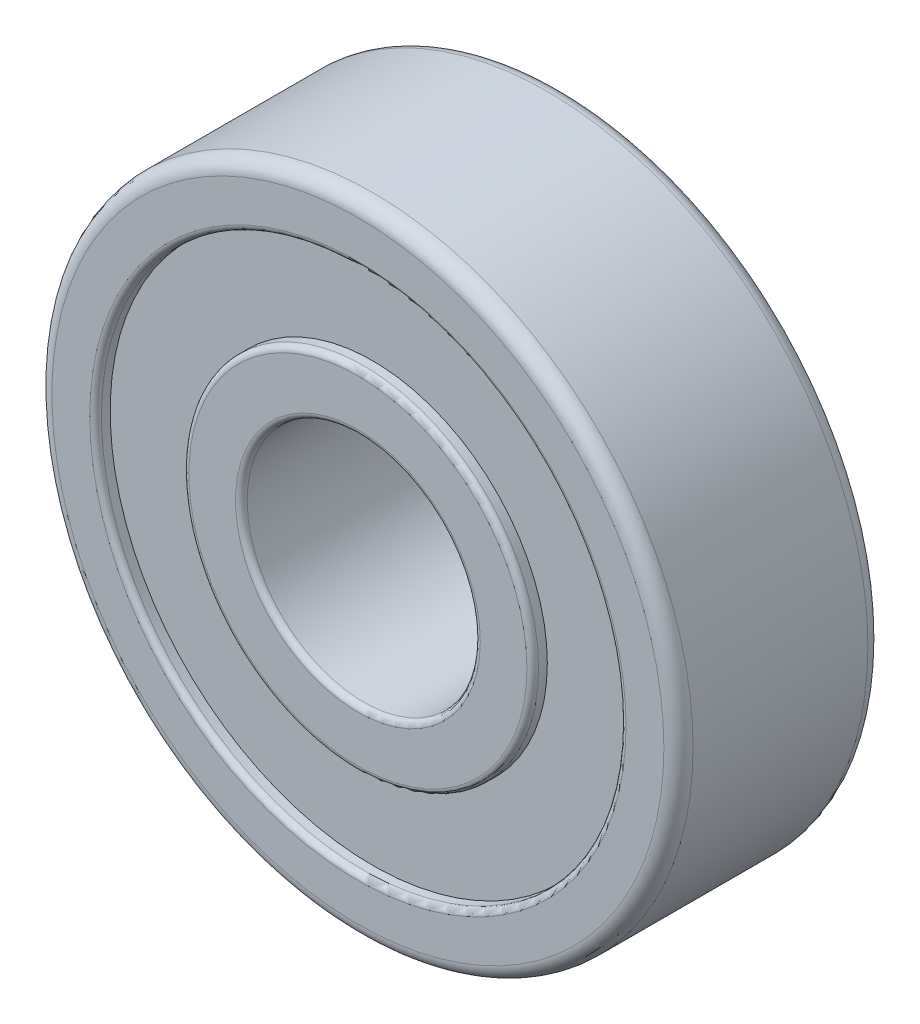
from build123d import *

# Parameters (mm, degrees)
IZIM1_R                     = 11
IZIM1_R_2                   = 4
Y_KSEKLIK_EKSTR_ZYON1_DEPTH = 7
IZIM2_R                     = 9
IZIM2_R_2                   = 6
KES_EKSTR_ZYON1_DEPTH       = 0.5
IZIM3_R                     = 9
IZIM3_R_2                   = 6
KES_EKSTR_ZYON2_DEPTH       = 0.5
RADYUS1_R                   = 0.5
RADYUS2_R                   = 0.2


with BuildPart() as part:
    # Çizim1 → Yükseklik-Ekstrüzyon1 (new body)
    with BuildSketch(Plane.XY):
        Circle(IZIM1_R)
        Circle(IZIM1_R_2, mode=Mode.SUBTRACT)
    extrude(amount=Y_KSEKLIK_EKSTR_ZYON1_DEPTH)

    # Çizim2 → Kes-Ekstrüzyon1 (cut)
    with BuildSketch(Plane(origin=(0, 0, 0), x_dir=(-1, 0, 0), z_dir=(0, 0, -1))):
        Circle(IZIM2_R)
        Circle(IZIM2_R_2, mode=Mode.SUBTRACT)
    extrude(amount=-KES_EKSTR_ZYON1_DEPTH, mode=Mode.SUBTRACT)

    # Çizim3 → Kes-Ekstrüzyon2 (cut)
    with BuildSketch(Plane.XY.offset(7)):
        Circle(IZIM3_R)
        Circle(IZIM3_R_2, mode=Mode.SUBTRACT)
    extrude(amount=-KES_EKSTR_ZYON2_DEPTH, mode=Mode.SUBTRACT)

    # Radyus1
    radyus1_edges = [part.edges().sort_by_distance(p)[0] for p in [
        (-11, 0, 0),
        (-11, 0, 7),
    ]]
    fillet(radyus1_edges, radius=RADYUS1_R)

    # Radyus2
    radyus2_edges = [part.edges().sort_by_distance(p)[0] for p in [
        (9, 0, 0),
        (6, 0, 0),
        (-9, 0, 7),
        (-6, 0, 7),
        (-4, 0, 0),
        (-4, 0, 7),
    ]]
    fillet(radyus2_edges, radius=RADYUS2_R)


solid = part.part
